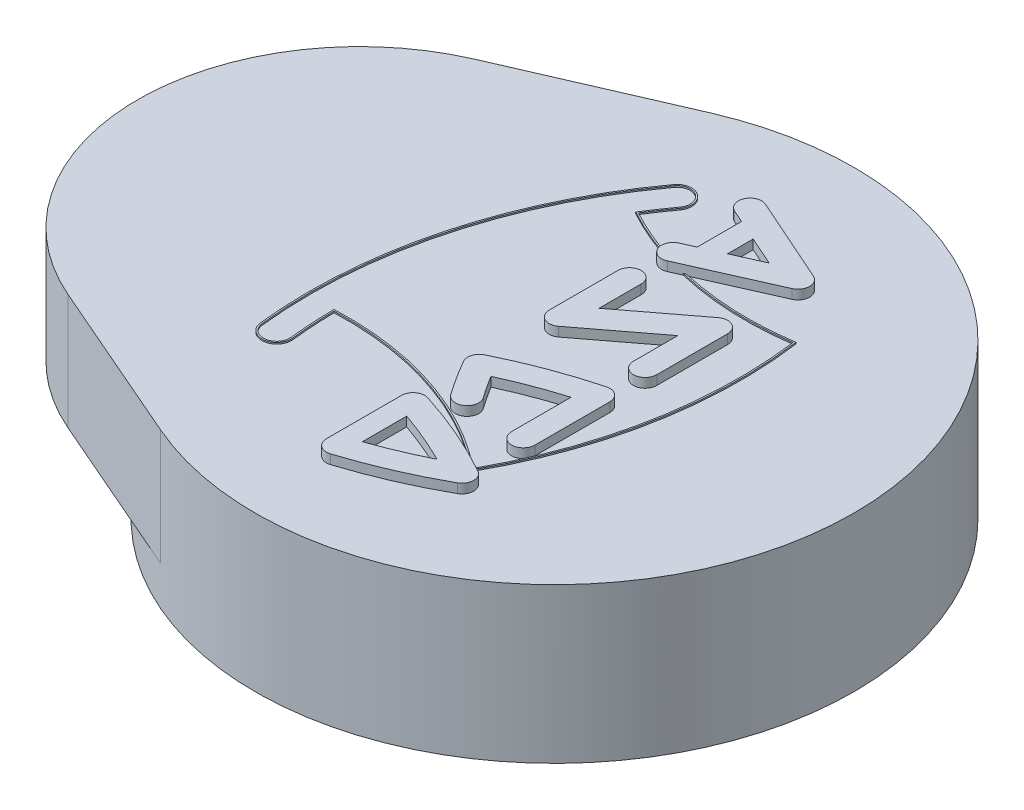
from build123d import *

# Parameters (mm, degrees)
SKETCH1_R           = 6.5151
BOSS_EXTRUDE1_DEPTH = 3.3676
BOSS_EXTRUDE2_DEPTH = 2.5146
BOSS_EXTRUDE3_DEPTH = 0.03175
BOSS_EXTRUDE4_DEPTH = 0.2032
BOSS_EXTRUDE5_DEPTH = 0.2032
BOSS_EXTRUDE6_DEPTH = 0.2032
BOSS_EXTRUDE7_DEPTH = 0.2032


with BuildPart() as part:
    # Sketch1 → Boss-Extrude1 (new body)
    with BuildSketch(Plane(origin=(0, 10.383607632, 0), x_dir=(-1, 0, 0), z_dir=(0, -1, 0))):
        with Locations((-86.1568, 0.188358884)):
            Circle(SKETCH1_R)
    extrude(amount=BOSS_EXTRUDE1_DEPTH)

    # Sketch2 → Boss-Extrude2 (add)
    with BuildSketch(Plane(origin=(0, 7.869007632, 0), x_dir=(1, 0, 0), z_dir=(0, 1, 0))):
        with BuildLine():
            Line((83.562463772, 6.164640968), (79.993269461, 4.615234502))
            ThreePointArc((79.993269461, 4.615234502), (77.089, 0.188358884), (79.993269461, -4.238516734))
            Line((79.993269461, -4.238516734), (83.562463772, -5.7879232))
            ThreePointArc((83.562463772, -5.7879232), (92.6719, 0.188358884), (83.562463772, 6.164640968))
        make_face()
    extrude(amount=BOSS_EXTRUDE2_DEPTH)

    # Sketch3 → Boss-Extrude3 (add)
    with BuildSketch(Plane(origin=(0, 10.415357632, 0), x_dir=(1, 0, 0), z_dir=(0, 1, 0))):
        with BuildLine():
            Line((86.379362148, 2.834929745), (86.331172499, 2.813512123))
            ThreePointArc((86.331172499, 2.813512123), (87.57388973, 2.642364143), (88.826675515, 2.706905023))
            ThreePointArc((88.826675515, 2.706905023), (88.743147222, -0.307968876), (87.717246323, -3.144158035))
            ThreePointArc((87.717246323, -3.144158035), (85.599615489, -1.990016157), (83.209989222, -1.664301363))
            ThreePointArc((83.209989222, -1.664301363), (83.226670097, -2.157743319), (83.268922831, -2.649655834))
            ThreePointArc((83.268922831, -2.649655834), (83.013982099, -2.96896843), (82.694669503, -2.714027698))
            ThreePointArc((82.694669503, -2.714027698), (82.970684724, 1.003656964), (84.577363687, 4.367575269))
            ThreePointArc((84.577363687, 4.367575269), (84.981125023, 4.430281687), (85.043831441, 4.026520351))
            ThreePointArc((85.043831441, 4.026520351), (84.845175329, 3.744205128), (84.656890151, 3.45486998))
            ThreePointArc((84.656890151, 3.45486998), (85.187045427, 3.19462014), (85.738141542, 2.982281574))
            ThreePointArc((85.738141542, 2.982281574), (85.741341744, 2.997904944), (85.745516089, 3.013296689))
            ThreePointArc((85.745516089, 3.013296689), (85.213902251, 3.217551458), (84.701749715, 3.466615834))
            ThreePointArc((84.701749715, 3.466615834), (84.880937437, 3.740370401), (85.069461538, 4.00778107))
            ThreePointArc((85.069461538, 4.00778107), (84.999864331, 4.455911764), (84.551733629, 4.386314602))
            ThreePointArc((84.551733629, 4.386314602), (82.940000597, 1.01181459), (82.663117122, -2.717564614))
            ThreePointArc((82.663117122, -2.717564614), (83.017519015, -3.000520811), (83.300475212, -2.646118918))
            ThreePointArc((83.300475212, -2.646118918), (83.259289868, -2.171130031), (83.242027928, -1.694671533))
            ThreePointArc((83.242027928, -1.694671533), (85.576128395, -2.015738406), (87.651108795, -3.131787359))
            ThreePointArc((87.651108795, -3.131787359), (87.69360158, -3.153679255), (87.735992687, -3.175767397))
            ThreePointArc((87.735992687, -3.175767397), (88.775617442, -0.307140697), (88.853849034, 2.743059067))
            ThreePointArc((88.853849034, 2.743059067), (87.612284437, 2.672606475), (86.379362148, 2.834929745))
        make_face()
    extrude(amount=-BOSS_EXTRUDE3_DEPTH)

    # Sketch4 → Boss-Extrude4 (add)
    with BuildSketch(Plane(origin=(0, 10.383607632, 0), x_dir=(1, 0, 0), z_dir=(0, 1, 0))):
        with BuildLine():
            Line((87.971211641, 4.006634675), (86.091611641, 4.842012453))
            ThreePointArc((86.091611641, 4.842012453), (85.756344283, 4.713063514), (85.8852933, 4.377796186))
            Line((85.8852933, 4.377796186), (86.1568, 4.257126542))
            Line((86.1568, 4.257126542), (86.1568, 3.291926542))
            Line((86.1568, 3.291926542), (85.8852933, 3.171256897))
            ThreePointArc((85.8852933, 3.171256897), (85.756344337, 2.835989594), (86.091611641, 2.707040631))
            Line((86.091611641, 2.707040631), (87.971211641, 3.542418409))
            ThreePointArc((87.971211641, 3.542418409), (88.12205247, 3.774526542), (87.971211641, 4.006634675))
        make_face()
        Polygon((87.24265, 3.774526542), (86.614, 4.053926542), (86.614, 3.495126542), align=None, mode=Mode.SUBTRACT)
    extrude(amount=BOSS_EXTRUDE4_DEPTH)

    # Sketch5 → Boss-Extrude5 (add)
    with BuildSketch(Plane(origin=(0, 10.383607632, 0), x_dir=(1, 0, 0), z_dir=(0, 1, 0))):
        with BuildLine():
            Line((88.12205247, 0.447338975), (88.12205247, 1.988743646))
            ThreePointArc((88.12205247, 1.988743646), (87.980866694, 2.216315505), (87.714265455, 2.19089595))
            Line((87.714265455, 2.19089595), (86.24245247, 1.071216772))
            Line((86.24245247, 1.071216772), (86.24245247, 1.988743646))
            ThreePointArc((86.24245247, 1.988743646), (85.98845247, 2.242743706), (85.73445247, 1.988743646))
            Line((85.73445247, 1.988743646), (85.73445247, 0.495012101))
            ThreePointArc((85.73445247, 0.495012101), (85.875638247, 0.267440242), (86.142239485, 0.292859797))
            Line((86.142239485, 0.292859797), (87.61405247, 1.412538975))
            Line((87.61405247, 1.412538975), (87.61405247, 0.447338975))
            ThreePointArc((87.61405247, 0.447338975), (87.86805247, 0.193338975), (88.12205247, 0.447338975))
        make_face()
    extrude(amount=BOSS_EXTRUDE5_DEPTH)

    # Sketch6 → Boss-Extrude6 (add)
    with BuildSketch(Plane(origin=(0, 10.383607632, 0), x_dir=(1, 0, 0), z_dir=(0, 1, 0))):
        with BuildLine():
            Line((88.12205247, -2.20349139), (88.12205247, -0.573641116))
            ThreePointArc((88.12205247, -0.573641116), (88.022972158, -0.372355522), (87.803029713, -0.328104884))
            ThreePointArc((87.803029713, -0.328104884), (86.82154331, -0.641121728), (85.876084624, -1.050270813))
            ThreePointArc((85.876084624, -1.050270813), (85.745367006, -1.204405708), (85.76854522, -1.405172817))
            ThreePointArc((85.76854522, -1.405172817), (86.002778478, -1.790740386), (86.25361081, -2.165721333))
            ThreePointArc((86.25361081, -2.165721333), (86.607396093, -2.227914435), (86.669589172, -1.874129148))
            ThreePointArc((86.669589172, -1.874129148), (86.505953581, -1.633172635), (86.349528836, -1.387473738))
            ThreePointArc((86.349528836, -1.387473738), (86.973563185, -1.12669528), (87.61405247, -0.909444852))
            Line((87.61405247, -0.909444852), (87.61405247, -2.20349139))
            ThreePointArc((87.61405247, -2.20349139), (87.86805247, -2.45749139), (88.12205247, -2.20349139))
        make_face()
    extrude(amount=BOSS_EXTRUDE6_DEPTH)

    # Sketch7 → Boss-Extrude7 (add)
    with BuildSketch(Plane(origin=(0, 10.383607632, 0), x_dir=(1, 0, 0), z_dir=(0, 1, 0))):
        with BuildLine():
            Line((85.73445247, -2.721325206), (85.73445247, -4.351175481))
            ThreePointArc((85.73445247, -4.351175481), (85.838455656, -4.55615586), (86.065294641, -4.593273149))
            ThreePointArc((86.065294641, -4.593273149), (87.050038854, -4.224609495), (87.992239729, -3.75782093))
            ThreePointArc((87.992239729, -3.75782093), (88.12205247, -3.536250363), (87.992239763, -3.314679777))
            ThreePointArc((87.992239763, -3.314679777), (87.050038872, -2.8478912), (86.065294641, -2.479227539))
            ThreePointArc((86.065294641, -2.479227539), (85.838455656, -2.516344828), (85.73445247, -2.721325206))
        make_face()
        with BuildLine():
            Line((86.1822, -3.053650344), (86.1822, -4.018850344))
            ThreePointArc((86.1822, -4.018850344), (86.761323847, -3.795601976), (87.325204148, -3.536250344))
            ThreePointArc((87.325204148, -3.536250344), (86.761323847, -3.276898711), (86.1822, -3.053650344))
        make_face(mode=Mode.SUBTRACT)
    extrude(amount=BOSS_EXTRUDE7_DEPTH)


solid = part.part
